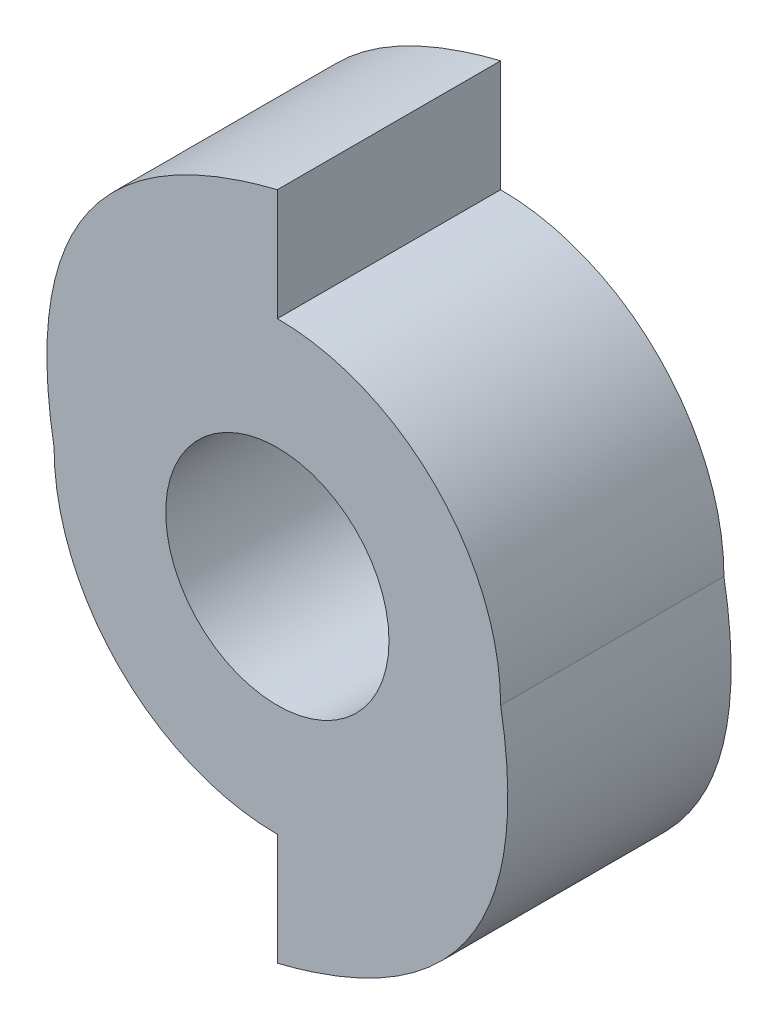
from build123d import *

# Parameters (mm, degrees)
SKETCH2_R           = 3.175
BOSS_EXTRUDE1_DEPTH = 6.35


with BuildPart() as part:
    # Sketch2 → Boss-Extrude1 (new body)
    with BuildSketch(Plane.XY):
        with BuildLine():
            add(Edge.make_bspline(
                [(88.748610912, 21.468378691), (87.390018144, 29.081992428), (95.098610912, 30.993378691)],
                knots=[0, 0, 0, 1, 1, 1], degree=2))
            Line((95.098610912, 30.993378691), (95.098610912, 27.818378691))
            ThreePointArc((95.098610912, 27.818378691), (99.588738973, 25.958506751), (101.448610912, 21.468378691))
            add(Edge.make_bspline(
                [(101.448610912, 21.468378691), (102.807203681, 13.854764953), (95.098610912, 11.943378691)],
                knots=[0, 0, 0, 1, 1, 1], degree=2))
            Line((95.098610912, 11.943378691), (95.098610912, 15.118378691))
            ThreePointArc((95.098610912, 15.118378691), (90.608482852, 16.97825063), (88.748610912, 21.468378691))
        make_face()
        with Locations((95.098610912, 21.468378691)):
            Circle(SKETCH2_R, mode=Mode.SUBTRACT)
    extrude(amount=BOSS_EXTRUDE1_DEPTH)


solid = part.part
